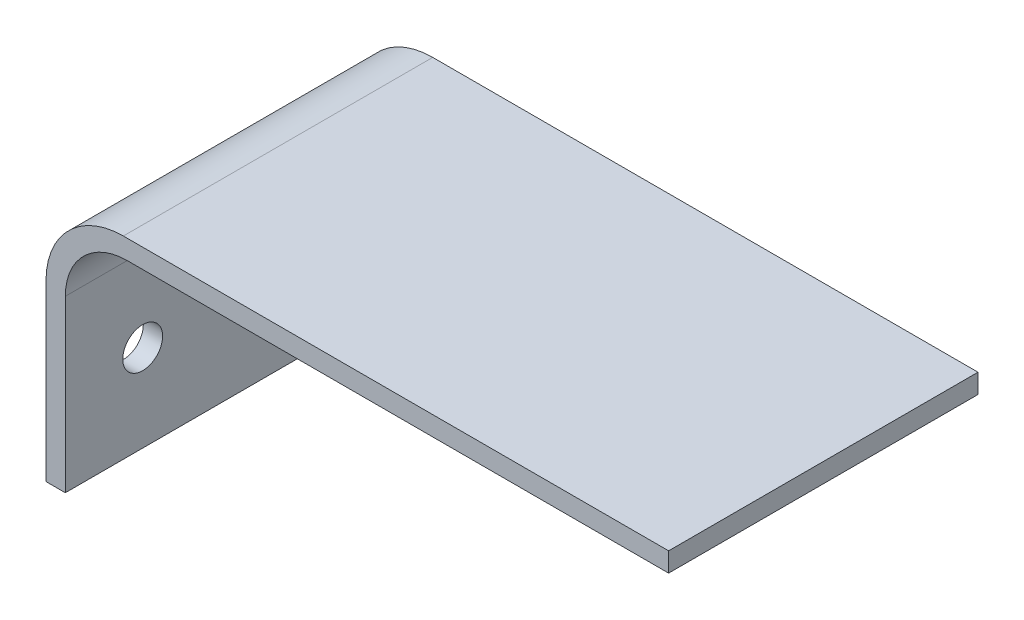
from build123d import *

# Parameters (mm, degrees)
BOSS_EXTRUDE1_DEPTH = 101.6
SKETCH2_R           = 6.54812
CUT_EXTRUDE1_DEPTH  = 304.8


with BuildPart() as part:
    # Sketch1 → Boss-Extrude1 (new body)
    with BuildSketch(Plane.XY):
        with BuildLine():
            Line((-76.777987096, 41.427423626), (102.292012904, 41.427423626))
            Line((102.292012904, 41.427423626), (102.292012904, 35.077423626))
            Line((102.292012904, 35.077423626), (-75.507987096, 35.077423626))
            ThreePointArc((-75.507987096, 35.077423626), (-89.87639689, 29.12583342), (-95.827987096, 14.757423626))
            Line((-95.827987096, 14.757423626), (-95.827987096, -41.122576374))
            Line((-95.827987096, -41.122576374), (-102.177987096, -41.122576374))
            Line((-102.177987096, -41.122576374), (-102.177987096, 16.027423626))
            ThreePointArc((-102.177987096, 16.027423626), (-94.738499338, 33.987935868), (-76.777987096, 41.427423626))
        make_face()
    extrude(amount=BOSS_EXTRUDE1_DEPTH)

    # Sketch2 → Cut-Extrude1 (cut)
    with BuildSketch(Plane.ZY.offset(102.177987096)):
        with Locations((25.4, -12.547576374)):
            Circle(SKETCH2_R)
        with Locations((76.2, -12.547576374)):
            Circle(SKETCH2_R)
    extrude(amount=-CUT_EXTRUDE1_DEPTH, mode=Mode.SUBTRACT)


solid = part.part
